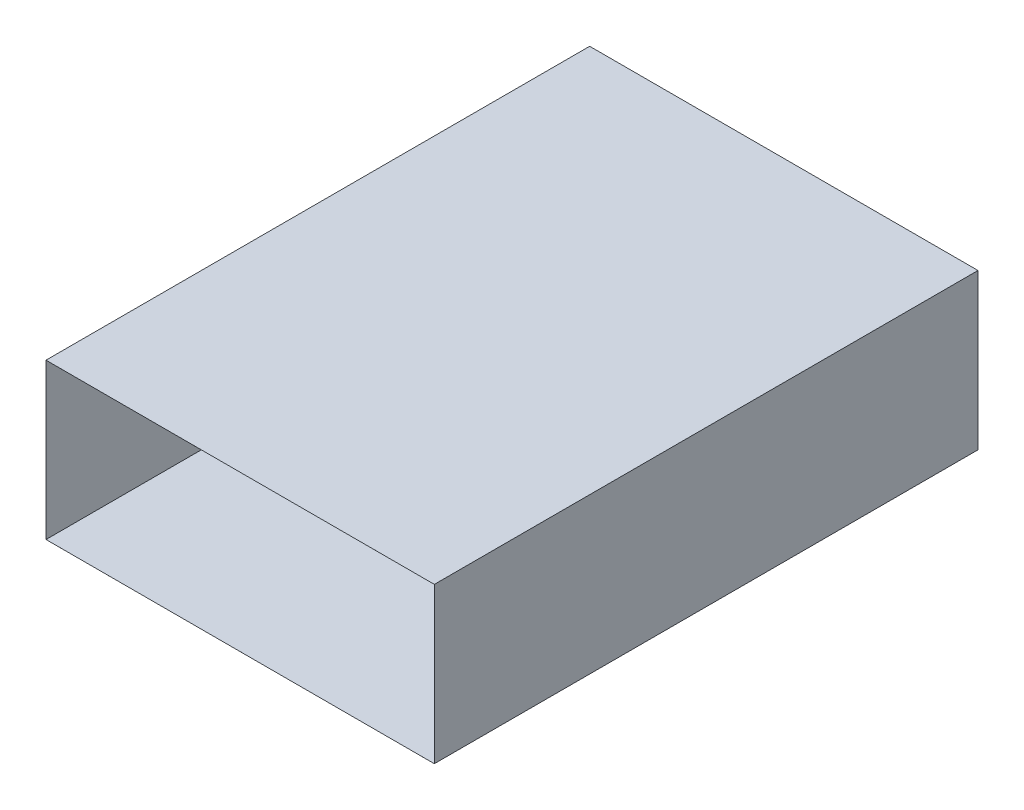
from build123d import *

# Parameters (mm, degrees)
ESQUISSE1_W        = 250.002
ESQUISSE1_H        = 100.002
ESQUISSE1_W_2      = 250
ESQUISSE1_H_2      = 100
EXTRU_MINCE1_DEPTH = 350


with BuildPart() as part:
    # Esquisse1 → Extru.-Mince1 (new body)
    with BuildSketch(Plane.XY):
        Rectangle(ESQUISSE1_W, ESQUISSE1_H)
        Rectangle(ESQUISSE1_W_2, ESQUISSE1_H_2, mode=Mode.SUBTRACT)
    extrude(amount=EXTRU_MINCE1_DEPTH)


solid = part.part
